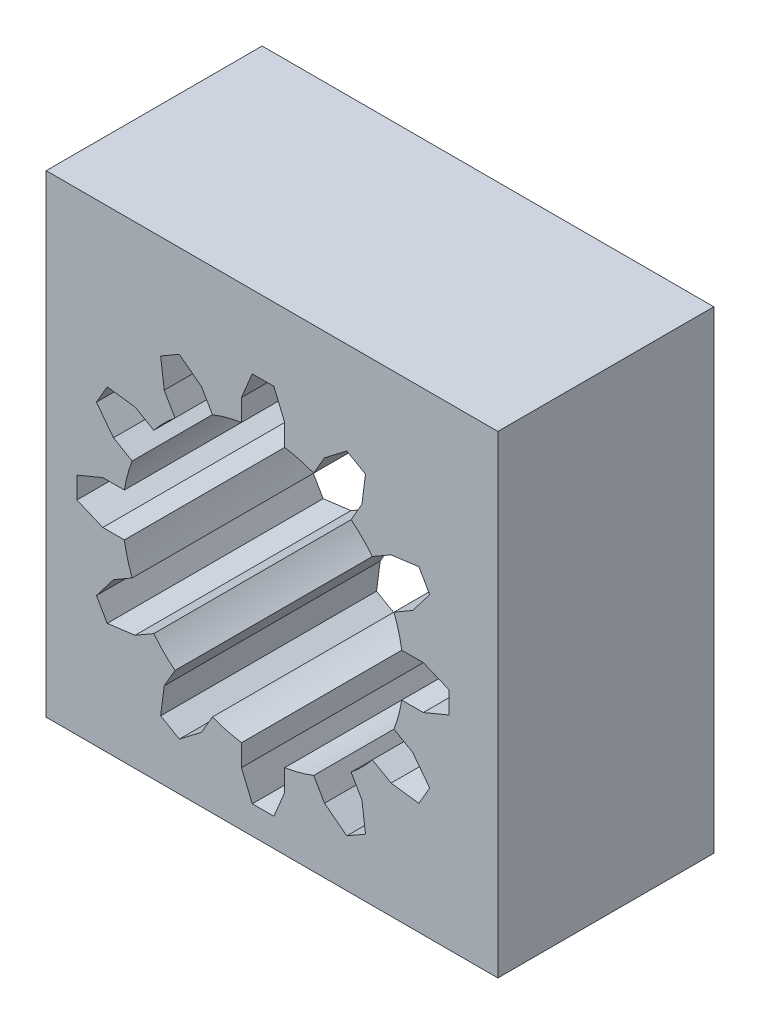
from build123d import *

# Parameters (mm, degrees)
SKETCH1_W           = 20.917422255
SKETCH1_H           = 21.921735574
BOSS_EXTRUDE1_DEPTH = 5


with BuildPart() as part:
    # Sketch1 → Boss-Extrude1 (new body, symmetric)
    with BuildSketch(Plane.XY):
        with Locations((0.415577926, 1.038944814)):
            Rectangle(SKETCH1_W, SKETCH1_H)
        with BuildLine():
            Line((-1, 6.422616289), (-1, 7.422616289))
            Line((-1, 7.422616289), (-0.5, 8.622616289))
            Line((-0.5, 8.622616289), (0.5, 8.622616289))
            Line((0.5, 8.622616289), (1, 7.422616289))
            Line((1, 7.422616289), (1, 6.422616289))
            ThreePointArc((1, 6.422616289), (1.682323793, 6.278517871), (2.345282741, 6.062148865))
            Line((2.345282741, 6.062148865), (2.845282741, 6.928174269))
            Line((2.845282741, 6.928174269), (3.878295443, 7.717404754))
            Line((3.878295443, 7.717404754), (4.744320847, 7.217404754))
            Line((4.744320847, 7.217404754), (4.577333548, 5.928174269))
            Line((4.577333548, 5.928174269), (4.077333548, 5.062148865))
            ThreePointArc((4.077333548, 5.062148865), (4.596194078, 4.596194078), (5.062148865, 4.077333548))
            Line((5.062148865, 4.077333548), (5.928174269, 4.577333548))
            Line((5.928174269, 4.577333548), (7.217404754, 4.744320847))
            Line((7.217404754, 4.744320847), (7.717404754, 3.878295443))
            Line((7.717404754, 3.878295443), (6.928174269, 2.845282741))
            Line((6.928174269, 2.845282741), (6.062148865, 2.345282741))
            ThreePointArc((6.062148865, 2.345282741), (6.278517871, 1.682323793), (6.422616289, 1))
            Line((6.422616289, 1), (7.422616289, 1))
            Line((7.422616289, 1), (8.622616289, 0.5))
            Line((8.622616289, 0.5), (8.622616289, -0.5))
            Line((8.622616289, -0.5), (7.422616289, -1))
            Line((7.422616289, -1), (6.422616289, -1))
            ThreePointArc((6.422616289, -1), (6.278517871, -1.682323793), (6.062148865, -2.345282741))
            Line((6.062148865, -2.345282741), (6.928174269, -2.845282741))
            Line((6.928174269, -2.845282741), (7.717404754, -3.878295443))
            Line((7.717404754, -3.878295443), (7.217404754, -4.744320847))
            Line((7.217404754, -4.744320847), (5.928174269, -4.577333548))
            Line((5.928174269, -4.577333548), (5.062148865, -4.077333548))
            ThreePointArc((5.062148865, -4.077333548), (4.596194078, -4.596194078), (4.077333548, -5.062148865))
            Line((4.077333548, -5.062148865), (4.577333548, -5.928174269))
            Line((4.577333548, -5.928174269), (4.744320847, -7.217404754))
            Line((4.744320847, -7.217404754), (3.878295443, -7.717404754))
            Line((3.878295443, -7.717404754), (2.845282741, -6.928174269))
            Line((2.845282741, -6.928174269), (2.345282741, -6.062148865))
            ThreePointArc((2.345282741, -6.062148865), (1.682323793, -6.278517871), (1, -6.422616289))
            Line((1, -6.422616289), (1, -7.422616289))
            Line((1, -7.422616289), (0.5, -8.622616289))
            Line((0.5, -8.622616289), (-0.5, -8.622616289))
            Line((-0.5, -8.622616289), (-1, -7.422616289))
            Line((-1, -7.422616289), (-1, -6.422616289))
            ThreePointArc((-1, -6.422616289), (-1.682323793, -6.278517871), (-2.345282741, -6.062148865))
            Line((-2.345282741, -6.062148865), (-2.845282741, -6.928174269))
            Line((-2.845282741, -6.928174269), (-3.878295443, -7.717404754))
            Line((-3.878295443, -7.717404754), (-4.744320847, -7.217404754))
            Line((-4.744320847, -7.217404754), (-4.577333548, -5.928174269))
            Line((-4.577333548, -5.928174269), (-4.077333548, -5.062148865))
            ThreePointArc((-4.077333548, -5.062148865), (-4.596194078, -4.596194078), (-5.062148865, -4.077333548))
            Line((-5.062148865, -4.077333548), (-5.928174269, -4.577333548))
            Line((-5.928174269, -4.577333548), (-7.217404754, -4.744320847))
            Line((-7.217404754, -4.744320847), (-7.717404754, -3.878295443))
            Line((-7.717404754, -3.878295443), (-6.928174269, -2.845282741))
            Line((-6.928174269, -2.845282741), (-6.062148865, -2.345282741))
            ThreePointArc((-6.062148865, -2.345282741), (-6.278517871, -1.682323793), (-6.422616289, -1))
            Line((-6.422616289, -1), (-7.422616289, -1))
            Line((-7.422616289, -1), (-8.622616289, -0.5))
            Line((-8.622616289, -0.5), (-8.622616289, 0.5))
            Line((-8.622616289, 0.5), (-7.422616289, 1))
            Line((-7.422616289, 1), (-6.422616289, 1))
            ThreePointArc((-6.422616289, 1), (-6.278517871, 1.682323793), (-6.062148865, 2.345282741))
            Line((-6.062148865, 2.345282741), (-6.928174269, 2.845282741))
            Line((-6.928174269, 2.845282741), (-7.717404754, 3.878295443))
            Line((-7.717404754, 3.878295443), (-7.217404754, 4.744320847))
            Line((-7.217404754, 4.744320847), (-5.928174269, 4.577333548))
            Line((-5.928174269, 4.577333548), (-5.062148865, 4.077333548))
            ThreePointArc((-5.062148865, 4.077333548), (-4.596194078, 4.596194078), (-4.077333548, 5.062148865))
            Line((-4.077333548, 5.062148865), (-4.577333548, 5.928174269))
            Line((-4.577333548, 5.928174269), (-4.744320847, 7.217404754))
            Line((-4.744320847, 7.217404754), (-3.878295443, 7.717404754))
            Line((-3.878295443, 7.717404754), (-2.845282741, 6.928174269))
            Line((-2.845282741, 6.928174269), (-2.345282741, 6.062148865))
            ThreePointArc((-2.345282741, 6.062148865), (-1.682323793, 6.278517871), (-1, 6.422616289))
        make_face(mode=Mode.SUBTRACT)
    extrude(amount=BOSS_EXTRUDE1_DEPTH, both=True)


solid = part.part
